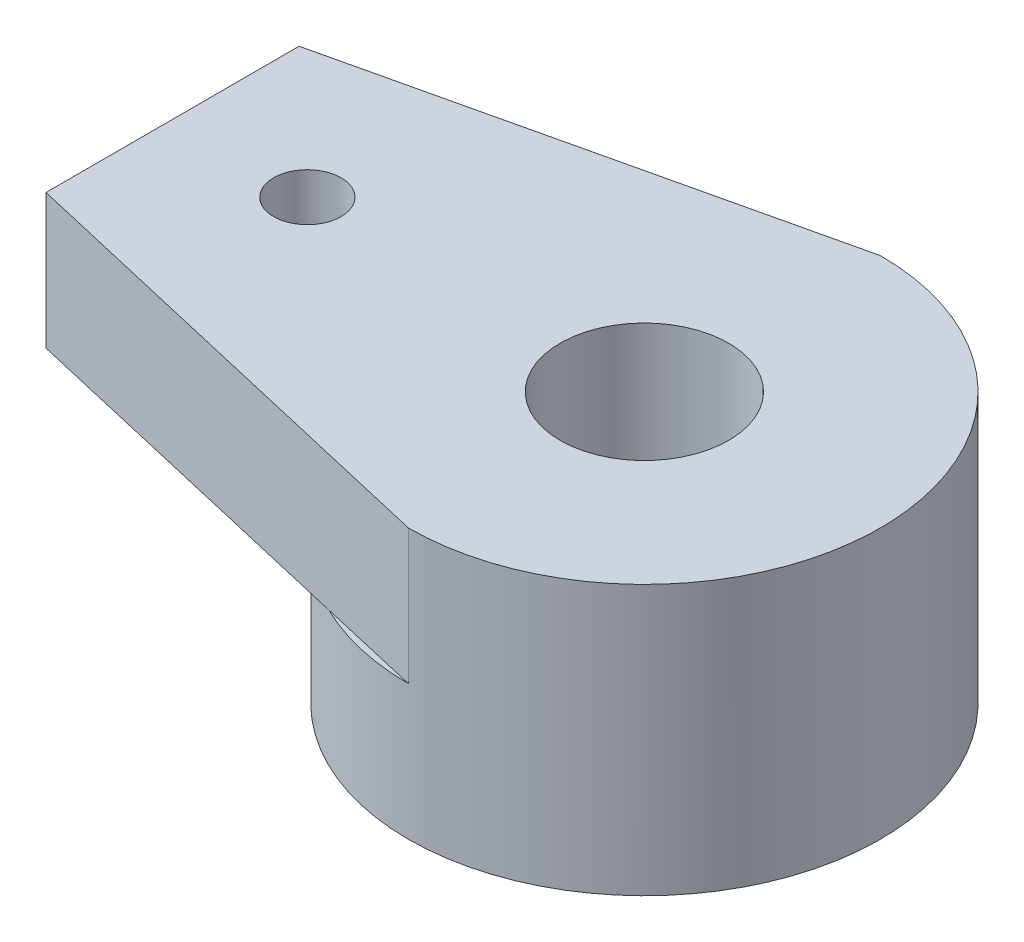
from build123d import *

# Parameters (mm, degrees)
SKETCH1_R           = 3.5
SKETCH1_R_2         = 2.25
BOSS_EXTRUDE1_DEPTH = 2
SKETCH2_R           = 1.25
SKETCH2_R_2         = 0.5
BOSS_EXTRUDE3_DEPTH = 2


with BuildPart() as part:
    # Sketch1 → Boss-Extrude1 (new body)
    with BuildSketch(Plane(origin=(0, 0, 0), x_dir=(1, 0, 0), z_dir=(0, 1, 0))):
        Circle(SKETCH1_R)
        Circle(SKETCH1_R_2, mode=Mode.SUBTRACT)
    extrude(amount=BOSS_EXTRUDE1_DEPTH)

    # Sketch2 → Boss-Extrude3 (add)
    with BuildSketch(Plane(origin=(0, 2, 0), x_dir=(1, 0, 0), z_dir=(0, 1, 0))):
        with BuildLine():
            Line((-7.000925654, 1.878025645), (-6.999074346, -1.878025645))
            Line((-6.999074346, -1.878025645), (0, -3.5))
            ThreePointArc((0, -3.5), (3.5, 0), (0, 3.5))
            Line((0, 3.5), (-7.000925654, 1.878025645))
        make_face()
        Circle(SKETCH2_R, mode=Mode.SUBTRACT)
        with Locations((-5, 0)):
            Circle(SKETCH2_R_2, mode=Mode.SUBTRACT)
    extrude(amount=BOSS_EXTRUDE3_DEPTH)


solid = part.part
